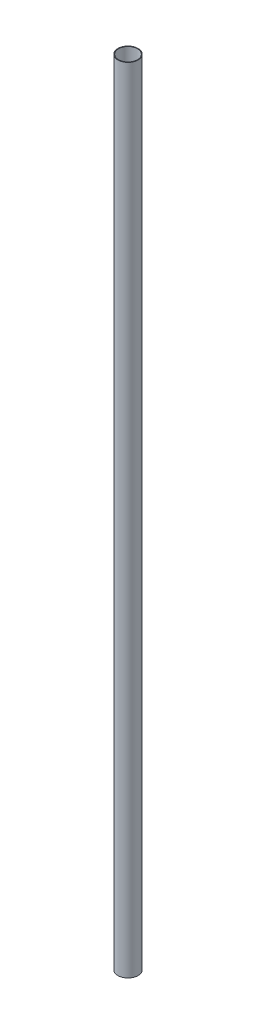
from build123d import *

# Parameters (mm, degrees)
SKETCH1_R           = 20.955
SKETCH1_R_2         = 19.685
BOSS_EXTRUDE1_DEPTH = 1651


with BuildPart() as part:
    # Sketch1 → Boss-Extrude1 (new body)
    with BuildSketch(Plane(origin=(0, 0, 0), x_dir=(1, 0, 0), z_dir=(0, 1, 0))):
        Circle(SKETCH1_R)
        Circle(SKETCH1_R_2, mode=Mode.SUBTRACT)
    extrude(amount=BOSS_EXTRUDE1_DEPTH)


solid = part.part
